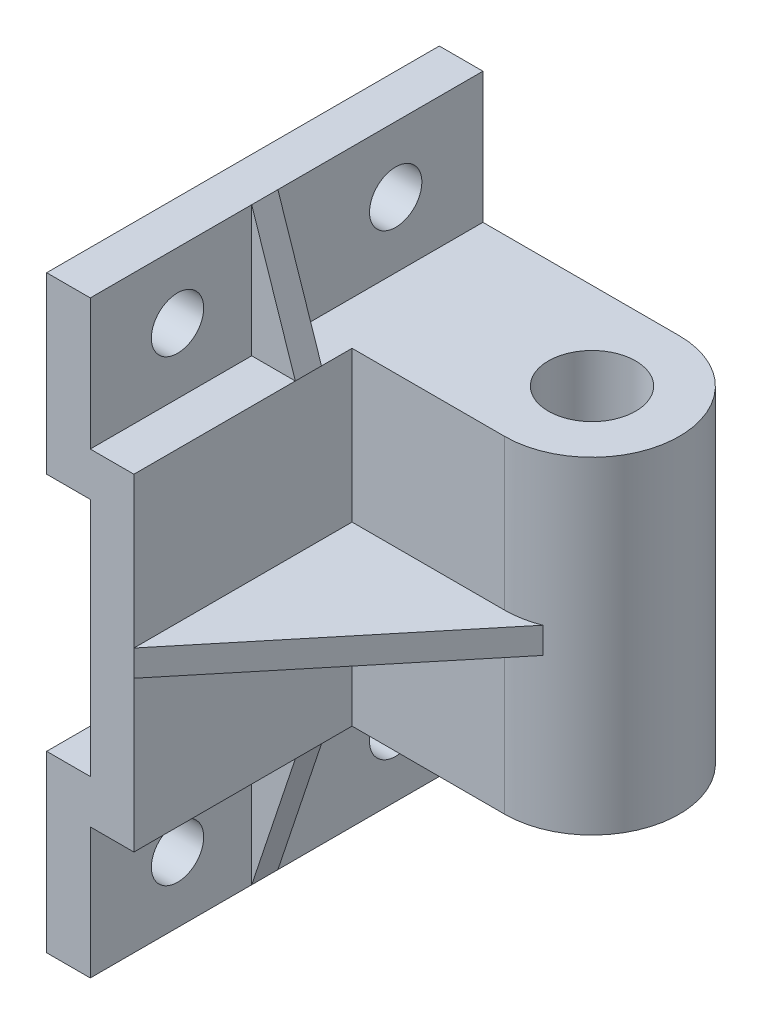
from build123d import *

# Parameters (mm, degrees)
Y_KSEKLIK_EKSTR_ZYON1_DEPTH = 45
Y_KSEKLIK_EKSTR_ZYON2_DEPTH = 75
IZIM3_R                     = 10
KES_EKSTR_ZYON1_DEPTH       = 75
IZIM4_R                     = 6
KES_EKSTR_ZYON2_DEPTH       = 11
Y_KSEKLIK_EKSTR_ZYON3_DEPTH = 6
Y_KSEKLIK_EKSTR_ZYON4_DEPTH = 3


with BuildPart() as part:
    # Çizim1 → Yükseklik-Ekstrüzyon1 (new body, symmetric)
    with BuildSketch(Plane.XY):
        Polygon((0, 0), (0, -75), (-10, -75), (-10, -105), (-20, -105), (-20, -65), (-10, -65), (-10, -10), (-20, -10), (-20, 30), (-10, 30), (-10, 0), align=None)
    extrude(amount=Y_KSEKLIK_EKSTR_ZYON1_DEPTH, both=True)

    # Çizim2 → Yükseklik-Ekstrüzyon2 (add)
    with BuildSketch(Plane(origin=(0, 0, 0), x_dir=(1, 0, 0), z_dir=(0, 1, 0))):
        with BuildLine():
            Line((0, 45), (35, 45))
            ThreePointArc((35, 45), (55, 25), (35, 5))
            Line((35, 5), (0, 5))
            Line((0, 5), (0, 45))
        make_face()
    extrude(amount=-Y_KSEKLIK_EKSTR_ZYON2_DEPTH)

    # Çizim3 → Kes-Ekstrüzyon1 (cut)
    with BuildSketch(Plane(origin=(0, 0, 0), x_dir=(1, 0, 0), z_dir=(0, 1, 0))):
        with Locations((35, 25)):
            Circle(IZIM3_R)
    extrude(amount=-KES_EKSTR_ZYON1_DEPTH, mode=Mode.SUBTRACT)

    # Çizim4 → Kes-Ekstrüzyon2 (cut, through all)
    with BuildSketch(Plane(origin=(-10, 0, 0), x_dir=(0, 0, -1), z_dir=(1, 0, 0))):
        with Locations((-25, 15)):
            Circle(IZIM4_R)
        with Locations((25, 15)):
            Circle(IZIM4_R)
    kes_ekstr_zyon2 = extrude(amount=-KES_EKSTR_ZYON2_DEPTH, mode=Mode.SUBTRACT)

    # Aynalama1: Kes-Ekstrüzyon2 across plane
    add(kes_ekstr_zyon2.mirror(Plane.ZX.offset(-37.5)), mode=Mode.SUBTRACT)

    # Çizim5 → Yükseklik-Ekstrüzyon3 (add)
    with BuildSketch(Plane.XY.offset(8)):
        Polygon((-10, 30), (0, 0), (-10, 0), align=None)
    y_kseklik_ekstr_zyon3 = extrude(amount=-Y_KSEKLIK_EKSTR_ZYON3_DEPTH)

    # Aynalama2: Yükseklik-Ekstrüzyon3 across plane
    add(y_kseklik_ekstr_zyon3.mirror(Plane.ZX.offset(-37.5)))

    # Çizim6 → Yükseklik-Ekstrüzyon4 (add, symmetric)
    with BuildSketch(Plane(origin=(0, -37.5, 0), x_dir=(1, 0, 0), z_dir=(0, 1, 0))):
        Polygon((0, 9.626666966), (45, 9.626666966), (0, -45), align=None)
    extrude(amount=Y_KSEKLIK_EKSTR_ZYON4_DEPTH, both=True)


solid = part.part
